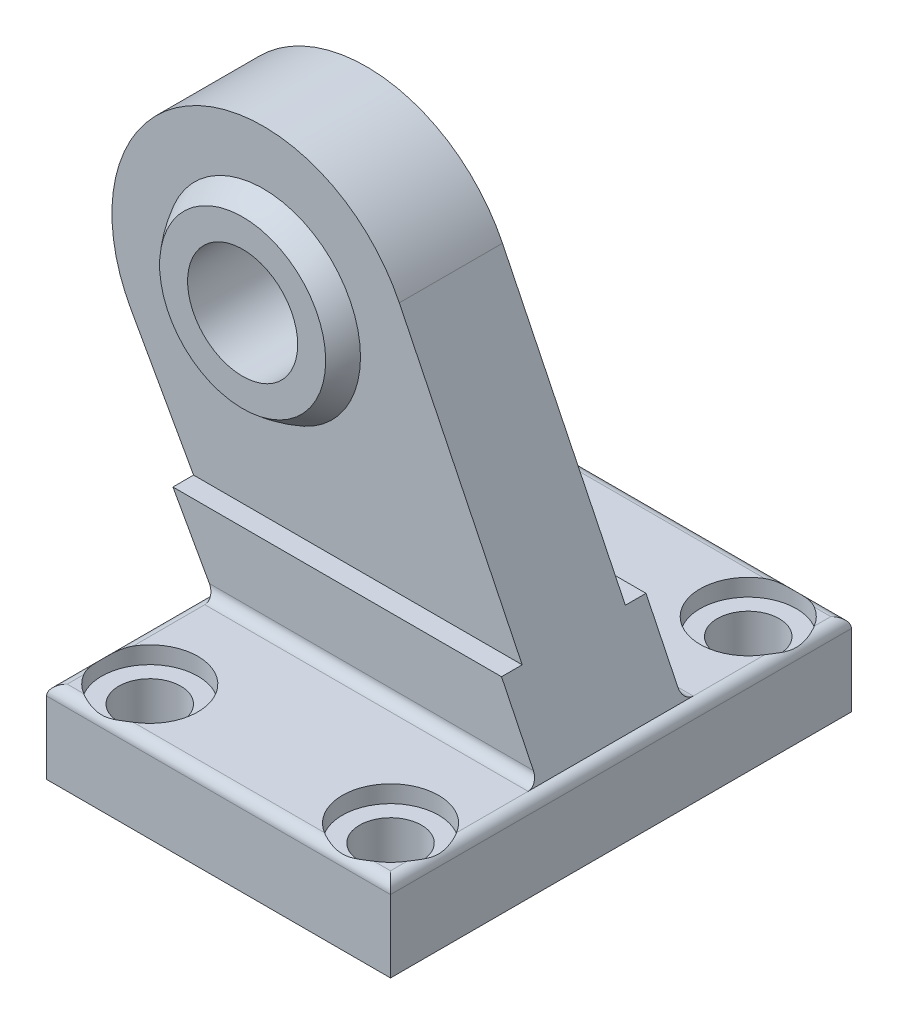
from build123d import *

# Parameters (mm, degrees)
BOSS_EXTRUDE1_DEPTH      = 33.5
BOSS_EXTRUDE1_DEPTH_BACK = 33.5
CUT_EXTRUDE1_DEPTH       = 67
CUT_EXTRUDE1_DEPTH_BACK  = 67
SKETCH4_W                = 8
SKETCH4_H                = 32


with BuildPart() as part:
    # Sketch1 → Boss-Extrude1 (new, two sides: drawn at the far end of the back side and taken through both)
    with BuildSketch(Plane.XY.offset(-BOSS_EXTRUDE1_DEPTH_BACK)):
        with BuildLine():
            Line((-38.714708847, 39.285758826), (-23.5, 12))
            ThreePointArc((-23.5, 12), (-24.560660172, 11.560660172), (-25, 10.5))
            Line((-25, 10.5), (-25, 0))
            Line((-25, 0), (25, 0))
            Line((25, 0), (25, 10.5))
            ThreePointArc((25, 10.5), (24.560660172, 11.560660172), (23.5, 12))
            Line((23.5, 12), (0.275280899, 59.640449438))
            ThreePointArc((0.275280899, 59.640449438), (-29.68120414, 69.502386579), (-38.714708847, 39.285758826))
        make_face()
    extrude(amount=BOSS_EXTRUDE1_DEPTH + BOSS_EXTRUDE1_DEPTH_BACK)

    # Sketch2 → Cut-Extrude1 (cut, two sides: drawn at the far end of the back side and taken through both)
    with BuildSketch(Plane(origin=(0, 0, 0), x_dir=(0, 0, -1), z_dir=(1, 0, 0)).offset(-CUT_EXTRUDE1_DEPTH_BACK)):
        with BuildLine():
            Line((-67, 100), (-67, -1))
            Line((-67, -1), (-33.5, -1))
            Line((-33.5, -1), (-33.5, 10.5))
            ThreePointArc((-33.5, 10.5), (-33.060660172, 11.560660172), (-32, 12))
            Line((-32, 12), (-12, 12))
            ThreePointArc((-12, 12), (-10.939339828, 12.439339828), (-10.5, 13.5))
            Line((-10.5, 13.5), (-10.5, 23))
            Line((-10.5, 23), (-7.5, 23))
            Line((-7.5, 23), (-7.5, 73))
            Line((-7.5, 73), (7.5, 73))
            Line((7.5, 73), (7.5, 23))
            Line((7.5, 23), (10.5, 23))
            Line((10.5, 23), (10.5, 13.5))
            ThreePointArc((10.5, 13.5), (10.939339828, 12.439339828), (12, 12))
            Line((12, 12), (32, 12))
            ThreePointArc((32, 12), (33.060660172, 11.560660172), (33.5, 10.5))
            Line((33.5, 10.5), (33.5, -1))
            Line((33.5, -1), (67, -1))
            Line((67, -1), (67, 100))
            Line((67, 100), (-67, 100))
        make_face()
    extrude(amount=CUT_EXTRUDE1_DEPTH + CUT_EXTRUDE1_DEPTH_BACK, mode=Mode.SUBTRACT)

    # Sketch3 → Revolve1 (revolve)
    with BuildSketch(Plane(origin=(0, 50, 0), x_dir=(1, 0, 0), z_dir=(0, 1, 0))):
        with BuildLine():
            Line((-19.5, 10.5), (-7.427303532, 10.5))
            ThreePointArc((-7.427303532, 10.5), (-3.5, 0), (-7.427303532, -10.5))
            Line((-7.427303532, -10.5), (-19.5, -10.5))
            Line((-19.5, -10.5), (-19.5, 10.5))
        make_face()
    revolve(axis=Axis((-19.5, 50, 10.5), (0, 0, -1)))

    # Sketch4 → Cut-Revolve1 (revolve, cut)
    with BuildSketch(Plane(origin=(0, 50, 0), x_dir=(1, 0, 0), z_dir=(0, 1, 0))):
        with Locations((-15.5, 0)):
            Rectangle(SKETCH4_W, SKETCH4_H)
    revolve(axis=Axis((-19.5, 50, 16), (0, 0, -1)), mode=Mode.SUBTRACT)

    # Sketch5 → Cut-Revolve2 (revolve, cut)
    with BuildSketch(Plane.XY.offset(26)):
        Polygon((17.5, 13), (24.5, 13), (24.5, 9.5), (22, 9.5), (22, -1), (17.5, -1), align=None)
    revolve(axis=Axis((17.5, -1, 26), (0, 1, 0)), mode=Mode.SUBTRACT)

    # Sketch6 → Cut-Revolve3 (revolve, cut)
    with BuildSketch(Plane.XY.offset(26)):
        Polygon((-17.5, 13), (-10.5, 13), (-10.5, 9.5), (-13, 9.5), (-13, -1), (-17.5, -1), align=None)
    revolve(axis=Axis((-17.5, -1, 26), (0, 1, 0)), mode=Mode.SUBTRACT)

    # Sketch7 → Cut-Revolve4 (revolve, cut)
    with BuildSketch(Plane.XY.offset(-26)):
        Polygon((-17.5, 13), (-10.5, 13), (-10.5, 9.5), (-13, 9.5), (-13, -1), (-17.5, -1), align=None)
    revolve(axis=Axis((-17.5, -1, -26), (0, 1, 0)), mode=Mode.SUBTRACT)

    # Sketch8 → Cut-Revolve5 (revolve, cut)
    with BuildSketch(Plane.XY.offset(-26)):
        Polygon((17.5, 13), (24.5, 13), (24.5, 9.5), (22, 9.5), (22, -1), (17.5, -1), align=None)
    revolve(axis=Axis((17.5, -1, -26), (0, 1, 0)), mode=Mode.SUBTRACT)


solid = part.part
